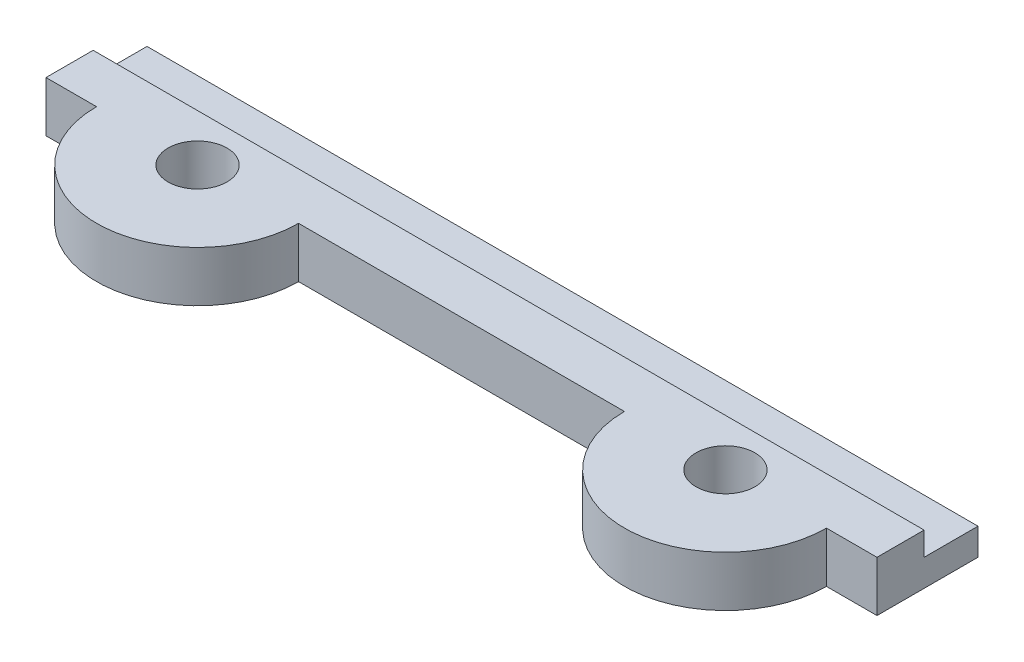
from build123d import *

# Parameters (mm, degrees)
SKETCH_1_R          = 1.75
EXTRUDE_1_DEPTH     = 3
SKETCH_2_W          = 49.355771561
SKETCH_2_H          = 3.2
CUT_EXTRUDE_1_DEPTH = 1.4


with BuildPart() as part:
    # Эскиз1 → Бобышка-Вытянуть1 (new body)
    with BuildSketch(Plane(origin=(0, 0, 0), x_dir=(1, 0, 0), z_dir=(0, 1, 0))):
        with BuildLine():
            Line((-24.459773103, 5.517931082), (24.895998458, 5.517931082))
            Line((24.895998458, 5.517931082), (24.895998458, -0.482068918))
            Line((24.895998458, -0.482068918), (21.895998458, -0.482068918))
            ThreePointArc((21.895998458, -0.482068918), (15.895998458, -6.482068918), (9.895998458, -0.482068918))
            Line((9.895998458, -0.482068918), (-9.459773103, -0.482068918))
            ThreePointArc((-9.459773103, -0.482068918), (-15.459773103, -6.482068918), (-21.459773103, -0.482068918))
            Line((-21.459773103, -0.482068918), (-24.459773103, -0.482068918))
            Line((-24.459773103, -0.482068918), (-24.459773103, 5.517931082))
        make_face()
        with Locations((15.895998458, -0.482068918)):
            Circle(SKETCH_1_R, mode=Mode.SUBTRACT)
        with Locations((-15.459773103, -0.482068918)):
            Circle(SKETCH_1_R, mode=Mode.SUBTRACT)
    extrude(amount=EXTRUDE_1_DEPTH)

    # Эскиз2 → Вырез-Вытянуть1 (cut)
    with BuildSketch(Plane(origin=(0, 3, 0), x_dir=(1, 0, 0), z_dir=(0, 1, 0))):
        with Locations((0.218112678, 3.917931082)):
            Rectangle(SKETCH_2_W, SKETCH_2_H)
    extrude(amount=-CUT_EXTRUDE_1_DEPTH, mode=Mode.SUBTRACT)


solid = part.part
